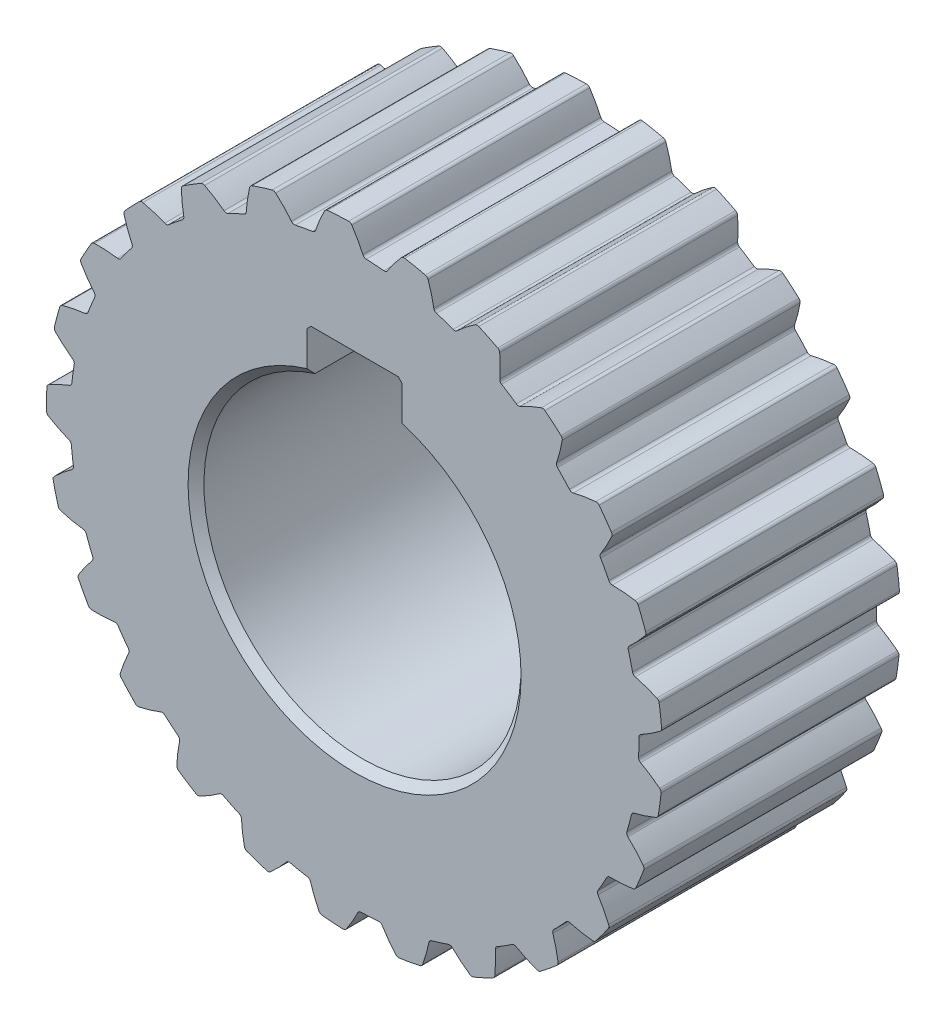
from build123d import *

# Parameters (mm, degrees)
SKETCH1_R                = 35.85
BOSS_EXTRUDE1_DEPTH      = 30
BOSS_EXTRUDE2_DEPTH      = 30
FILLET1_R                = 0.48
CIRPATTERN1_COUNT        = 25
FILLET1_OF_CIRPATTERN1_R = 0.48
CHAMFER1_SIZE            = 0.5
CHAMFER2_SIZE            = 1


with BuildPart() as part:
    # Sketch1 → Boss-Extrude1 (new body)
    with BuildSketch(Plane.XY):
        Circle(SKETCH1_R)
        with BuildLine():
            Line((6, 19.078784028), (6, 25))
            Line((6, 25), (-6, 25))
            Line((-6, 25), (-6, 19.078784028))
            ThreePointArc((-6, 19.078784028), (0, -20), (6, 19.078784028))
        make_face(mode=Mode.SUBTRACT)
    extrude(amount=BOSS_EXTRUDE1_DEPTH)

    # Sketch2 → Boss-Extrude2 (add)
    with BuildSketch(Plane.XY):
        with BuildLine():
            ThreePointArc((35.833660522, 1.082253952), (35.606652409, 4.169988514), (35.114077471, 7.226621848))
            add(Edge.make_bspline(
                [(35.114077471, 7.226621848), (35.137465191, 7.221030931), (35.277410926, 7.187262252), (35.533135946, 7.122159664), (35.900245875, 7.020630644), (36.362540181, 6.876985826), (36.808905507, 6.72706227), (37.270745226, 6.555639027), (37.69616913, 6.389406832), (38.053275563, 6.236162647), (38.260725023, 6.145338386), (38.367299222, 6.09750423), (38.368608389, 6.096916457)],
                knots=[0.405523248, 0.405523248, 0.405523248, 0.405523248, 0.405523248, 0.416499661, 0.471231937, 0.525964282, 0.580696616, 0.635428982, 0.690161387, 0.744893688, 0.799626082, 0.800306597, 0.800306597, 0.800306597, 0.800306597, 0.800306597], degree=4))
            ThreePointArc((38.368608389, 6.096916457), (38.586288594, 4.518941528), (38.739099664, 2.933369604))
            add(Edge.make_bspline(
                [(35.833660522, 1.082253952), (35.855123562, 1.09309746), (35.983479958, 1.158287705), (36.217242803, 1.280715501), (36.550959971, 1.464320222), (36.967554748, 1.710894048), (37.367200835, 1.95989622), (37.776934947, 2.233391762), (38.152438066, 2.493422623), (38.464473318, 2.725031747), (38.645323767, 2.861330829), (38.737961731, 2.932495244), (38.739099664, 2.933369604)],
                knots=[0.405523248, 0.405523248, 0.405523248, 0.405523248, 0.405523248, 0.416499661, 0.471231937, 0.525964282, 0.580696616, 0.635428982, 0.690161387, 0.744893688, 0.799626082, 0.800306597, 0.800306597, 0.800306597, 0.800306597, 0.800306597], degree=4))
        make_face()
    boss_extrude2 = extrude(amount=BOSS_EXTRUDE2_DEPTH)

    # Fillet1
    fillet1_edges = [part.edges().sort_by_distance(p)[0] for p in [
        (35.833660522, 1.082253952, 15),
        (38.739099664, 2.933369604, 15),
        (38.368608389, 6.096916457, 15),
        (35.114077471, 7.226621848, 15),
    ]]
    fillet(fillet1_edges, radius=FILLET1_R)

    # CirPattern1: Boss-Extrude2 ×25 about axis
    cirpattern1_axis = Axis((0, 0, 30), (0, 0, -1))
    for i in range(1, CIRPATTERN1_COUNT):
        add(boss_extrude2.rotate(cirpattern1_axis, i * 360 / CIRPATTERN1_COUNT))

    # Fillet1 of CirPattern1
    fillet1_of_cirpattern1_edges = [part.edges().sort_by_distance(p)[0] for p in [
        (34.977025796, -7.863216038, 15),
        (38.251538968, -6.79280992, 15),
        (38.679429467, -3.636514276, 15),
        (35.808091929, -1.73293173, 15),
        (31.922655903, -16.314611245, 15),
        (35.360493399, -16.092172215, 15),
        (36.559879739, -13.141449443, 15),
        (34.252152278, -10.583598835, 15),
        (26.862468137, -23.740899427, 15),
        (30.247617983, -24.380404147, 15),
        (32.143138309, -21.82065901, 15),
        (30.544023929, -18.769259501, 15),
        (20.114412704, -29.675459585, 15),
        (23.234173486, -31.136725621, 15),
        (25.706725285, -29.128796321, 15),
        (24.916702223, -25.775578564, 15),
        (12.102494746, -33.745401478, 15),
        (14.76084042, -35.936612112, 15),
        (17.655064168, -34.606664231, 15),
        (17.72377248, -31.16232323, 15),
        (3.330132532, -35.69499569, 15),
        (5.360029463, -38.478469098, 15),
        (8.494070439, -37.910068153, 15),
        (9.417192928, -34.59102452, 15),
        (-5.651474156, -35.401742046, 15),
        (-4.377571857, -38.602582357, 15),
        (-1.200636975, -38.831443069, 15),
        (0.51889651, -35.846244523, 15),
        (-14.277977937, -32.88406675, 15),
        (-13.840114238, -36.301153396, 15),
        (-10.819903952, -37.312895606, 15),
        (-8.412004084, -34.849113149, 15),
        (-22.007343855, -28.300164601, 15),
        (-22.433031341, -31.718789461, 15),
        (-19.75931657, -33.449841684, 15),
        (-16.814347524, -31.66228383, 15),
        (-28.35390742, -21.93805903, 15),
        (-29.616398582, -25.14341733, 15),
        (-27.45717866, -27.485011189, 15),
        (-24.16018367, -26.485996772, 15),
        (-32.918890704, -14.197504527, 15),
        (-34.938858579, -16.988191818, 15),
        (-33.429805233, -19.793196358, 15),
        (-29.987946621, -19.645497129, 15),
        (-35.415459018, -5.5648686, 15),
        (-38.065981594, -7.765535735, 15),
        (-37.301914198, -10.857702206, 15),
        (-33.931456599, -11.570598649, 15),
        (-35.686743793, 3.417428487, 15),
        (-38.80127899, 1.945057518, 15),
        (-38.830206706, -1.239978693, 15),
        (-35.742928366, -2.768676903, 15),
        (-33.715699208, 12.184995974, 15),
        (-37.098549325, 11.533435653, 15),
        (-37.91865452, 8.455657242, 15),
        (-35.308540492, 6.207210995, 15),
        (-29.626173245, 20.186935351, 15),
        (-33.064781368, 20.397125609, 15),
        (-34.624533815, 17.619993135, 15),
        (-32.655587162, 14.793076999, 15),
        (-23.675125859, 26.920455337, 15),
        (-26.953431593, 27.979189148, 15),
        (-29.154826311, 25.677200058, 15),
        (-27.950763193, 22.449439569, 15),
        (-16.236483245, 31.962464108, 15),
        (-19.148498584, 33.803217332, 15),
        (-21.853213845, 32.121014066, 15),
        (-21.489689976, 28.695221288, 15),
        (-7.777642674, 34.996153709, 15),
        (-10.140394985, 37.503265052, 15),
        (-13.178483583, 36.546546628, 15),
        (-13.678340504, 33.137976719, 15),
        (1.169895789, 35.830906266, 15),
        (-0.495133075, 38.846844701, 15),
        (-3.67570073, 38.675725257, 15),
        (-5.007530593, 35.498551201, 15),
        (10.043925398, 34.414271205, 15),
        (9.181239866, 37.749534229, 15),
        (6.058039917, 38.374765828, 15),
        (3.977920881, 35.628621156, 15),
        (18.286858235, 30.835260918, 15),
        (18.280721741, 34.280281689, 15),
        (15.411131637, 35.66257873, 15),
        (12.713424957, 33.520013811, 15),
        (25.380760515, 25.318757783, 15),
        (26.231558636, 28.657072975, 15),
        (23.795885278, 30.709580652, 15),
        (20.650097786, 29.30522072, 15),
        (30.879896268, 18.211383981, 15),
        (32.53417023, 21.233234974, 15),
        (30.685455932, 23.82698668, 15),
        (27.289249025, 23.249072834, 15),
        (34.43873457, 9.959721946, 15),
        (36.792540256, 12.475234728, 15),
        (35.646946536, 15.447255506, 15),
        (32.213716385, 15.732100198, 15),
    ]]
    fillet(fillet1_of_cirpattern1_edges, radius=FILLET1_OF_CIRPATTERN1_R)

    # Chamfer1
    chamfer1_edges = [part.edges().sort_by_distance(p)[0] for p in [
        (6, 25, 15),
        (-6, 25, 15),
    ]]
    chamfer(chamfer1_edges, length=CHAMFER1_SIZE)

    # Chamfer2
    chamfer2_edges = [part.edges().sort_by_distance(p)[0] for p in [
        (0, -20, 30),
        (0, -20, 0),
    ]]
    chamfer(chamfer2_edges, length=CHAMFER2_SIZE)


solid = part.part
